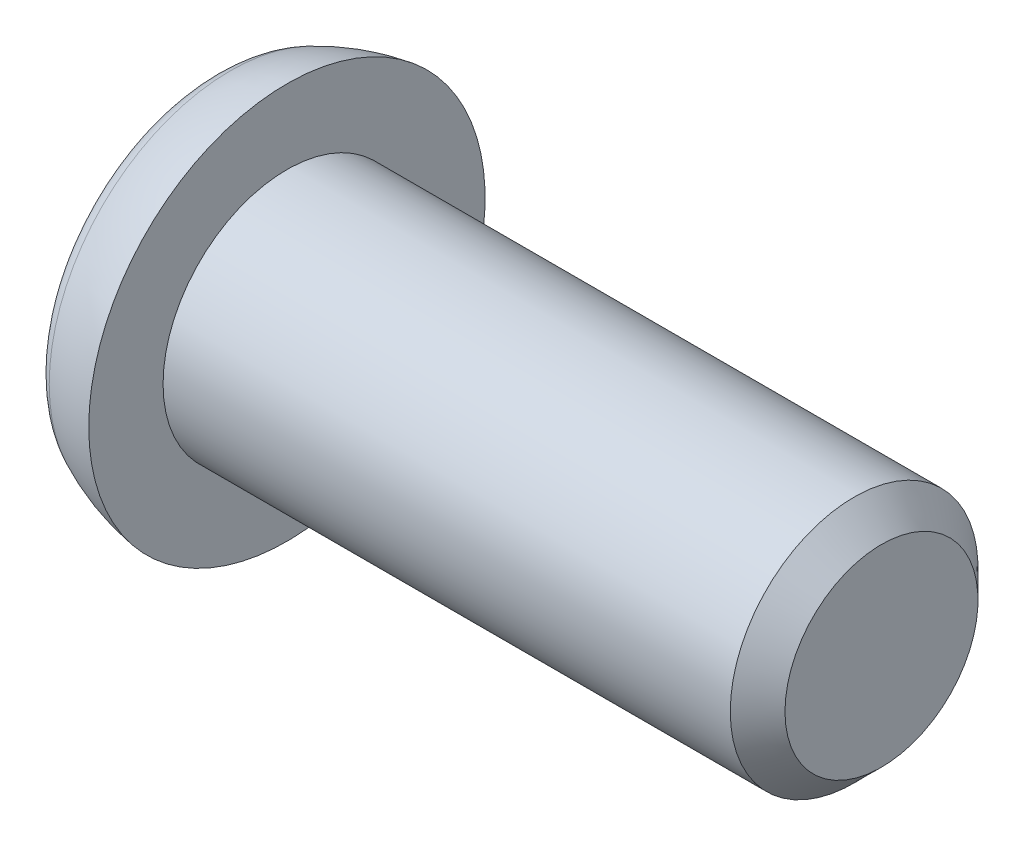
from build123d import *

# Parameters (mm, degrees)
CUT_EXTRUDE1_DEPTH      = 0.2
CUT_EXTRUDE1_DEPTH_BACK = 0.2
CUT_EXTRUDE2_DEPTH      = 0.2
CUT_EXTRUDE2_DEPTH_BACK = 0.2


with BuildPart() as part:
    # Sketch1 → Revolve1 (revolve)
    with BuildSketch(Plane.XY):
        with BuildLine():
            Line((-0.8, 0), (-0.8, 1.46601855))
            ThreePointArc((-0.8, 1.46601855), (-0.738085774, 1.679789478), (-0.571509952, 1.827383098))
            ThreePointArc((-0.571509952, 1.827383098), (-0.29223212, 1.93513645), (0, 2))
            Line((0, 2), (0, 1.25))
            Line((0, 1.25), (5.724, 1.25))
            Line((5.724, 1.25), (6, 0.974))
            Line((6, 0.974), (6, 0))
            Line((6, 0), (-0.8, 0))
        make_face()
    revolve(axis=Axis((6, 0, 0), (-1, 0, 0)))

    # Sketch2 → Cut-Extrude1 (cut, two sides: drawn at the far end of the back side and taken through both)
    with BuildSketch(Plane.XY.offset(-CUT_EXTRUDE1_DEPTH_BACK)):
        with BuildLine():
            Line((-0.8, 1), (-0.8, -1))
            ThreePointArc((-0.8, -1), (-0.115415221, -0.639534952), (0.32, 0))
            ThreePointArc((0.32, 0), (-0.115415221, 0.639534952), (-0.8, 1))
        make_face()
    extrude(amount=CUT_EXTRUDE1_DEPTH + CUT_EXTRUDE1_DEPTH_BACK, mode=Mode.SUBTRACT)

    # Sketch3 → Cut-Extrude2 (cut, two sides: drawn at the far end of the back side and taken through both)
    with BuildSketch(Plane(origin=(0, 0, 0), x_dir=(1, 0, 0), z_dir=(0, 1, 0)).offset(-CUT_EXTRUDE2_DEPTH_BACK)):
        with BuildLine():
            Line((-0.8, 1), (-0.8, -1))
            ThreePointArc((-0.8, -1), (-0.115415221, -0.639534952), (0.32, 0))
            ThreePointArc((0.32, 0), (-0.115415221, 0.639534952), (-0.8, 1))
        make_face()
    extrude(amount=CUT_EXTRUDE2_DEPTH + CUT_EXTRUDE2_DEPTH_BACK, mode=Mode.SUBTRACT)


solid = part.part
